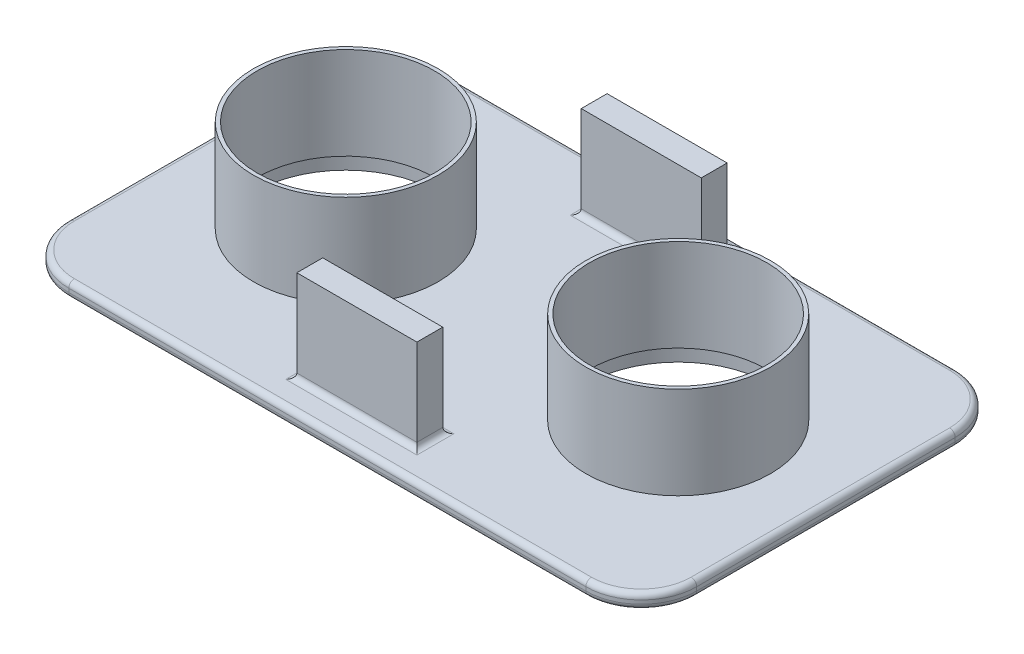
from build123d import *

# Parameters (mm, degrees)
SKETCH1_R           = 50
BOSS_EXTRUDE1_DEPTH = 8
SKETCH2_R           = 50
SKETCH2_W           = 65
SKETCH2_H           = 14
BOSS_EXTRUDE2_DEPTH = 50
SKETCH4_R           = 48
CUT_EXTRUDE1_DEPTH  = 59
FILLET2_R           = 3
FILLET3_R           = 3


with BuildPart() as part:
    # Sketch1 → Boss-Extrude1 (new body)
    with BuildSketch(Plane(origin=(0, 0, 0), x_dir=(1, 0, 0), z_dir=(0, 1, 0))):
        with BuildLine():
            Line((-140, 100), (140, 100))
            ThreePointArc((140, 100), (161.213203436, 91.213203436), (170, 70))
            Line((170, 70), (170, -70))
            ThreePointArc((170, -70), (161.213203436, -91.213203436), (140, -100))
            Line((140, -100), (-140, -100))
            ThreePointArc((-140, -100), (-161.213203436, -91.213203436), (-170, -70))
            Line((-170, -70), (-170, 70))
            ThreePointArc((-170, 70), (-161.213203436, 91.213203436), (-140, 100))
        make_face()
        with Locations((-90, 0)):
            Circle(SKETCH1_R, mode=Mode.SUBTRACT)
        with Locations((90, 0)):
            Circle(SKETCH1_R, mode=Mode.SUBTRACT)
    extrude(amount=BOSS_EXTRUDE1_DEPTH)

    # Sketch2 → Boss-Extrude2 (add)
    with BuildSketch(Plane(origin=(0, 8, 0), x_dir=(1, 0, 0), z_dir=(0, 1, 0))):
        with Locations((-90, 0)):
            Circle(SKETCH2_R)
        with Locations((90, 0)):
            Circle(SKETCH2_R)
        with Locations((0, -77)):
            Rectangle(SKETCH2_W, SKETCH2_H)
        with Locations((0, 77)):
            Rectangle(SKETCH2_W, SKETCH2_H)
    extrude(amount=BOSS_EXTRUDE2_DEPTH)

    # Sketch4 → Cut-Extrude1 (cut, through all)
    with BuildSketch(Plane(origin=(0, 58, 0), x_dir=(1, 0, 0), z_dir=(0, 1, 0))):
        with Locations((-90, 0)):
            Circle(SKETCH4_R)
        with Locations((90, 0)):
            Circle(SKETCH4_R)
    extrude(amount=-CUT_EXTRUDE1_DEPTH, mode=Mode.SUBTRACT)

    # Fillet2
    fillet2_edges = [part.edges().sort_by_distance(p)[0] for p in [
        (32.5, 8, -77),
        (0, 8, -84),
        (-32.5, 8, -77),
        (0, 8, -70),
        (-32.5, 8, 77),
        (0, 8, 84),
        (32.5, 8, 77),
        (0, 8, 70),
    ]]
    fillet(fillet2_edges, radius=FILLET2_R)

    # Fillet3
    fillet3_edges = [part.edges().sort_by_distance(p)[0] for p in [
        (170, 0, 0),
        (161.213203436, 0, 91.213203436),
        (0, 0, 100),
        (-161.213203436, 0, 91.213203436),
        (161.213203436, 8, 91.213203436),
        (170, 8, 0),
        (161.213203436, 8, -91.213203436),
        (0, 8, -100),
        (-161.213203436, 8, -91.213203436),
        (-170, 8, 0),
        (-161.213203436, 8, 91.213203436),
        (-170, 0, 0),
        (0, 8, 100),
        (-161.213203436, 0, -91.213203436),
        (0, 0, -100),
        (161.213203436, 0, -91.213203436),
    ]]
    fillet(fillet3_edges, radius=FILLET3_R)


solid = part.part
